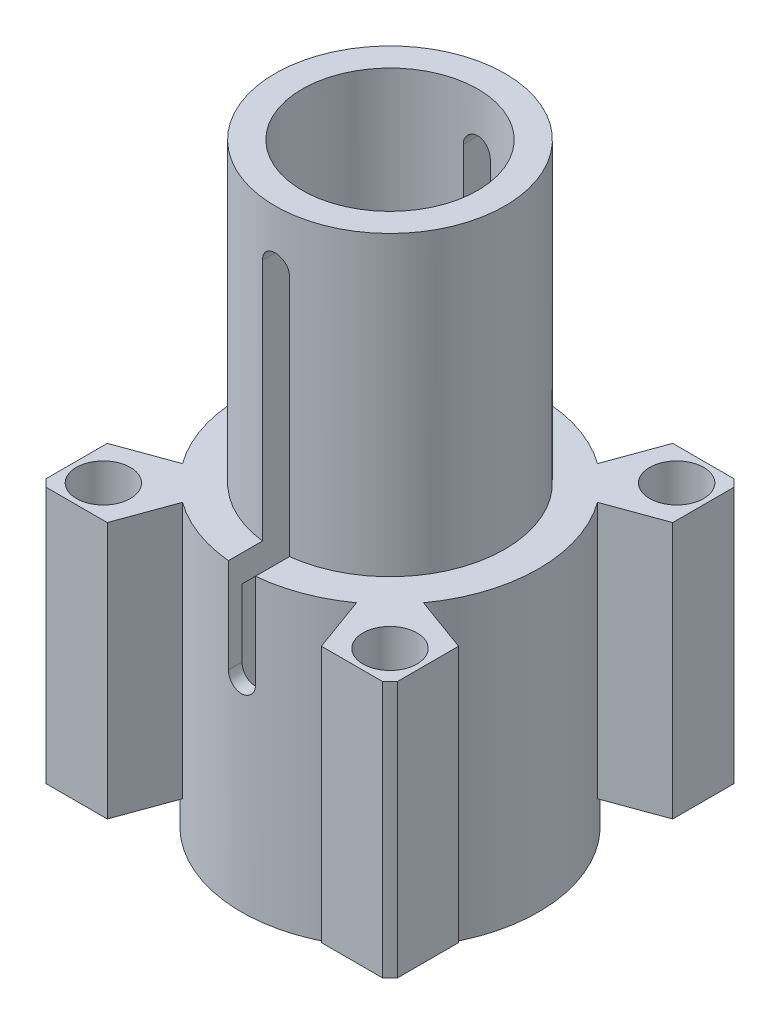
from build123d import *

# Parameters (mm, degrees)
ESQUISSE3_R      = 2
ESQUISSE3_R_2    = 10
EXTRUSION2_DEPTH = 19
EXTRUSION4_DEPTH = 27


with BuildPart() as part:
    # Esquisse1 → Révolution1 (revolve)
    with BuildSketch(Plane.XY):
        Polygon((-6.5, 17), (-6.5, 41), (-8.5, 41), (-8.5, 19), (-11, 19), (-11, -3), (-10, -3), (-10, 17), align=None)
    revolve(axis=Axis((0, 0, 0), (0, 1, 0)))

    # Esquisse3 → Extrusion2 (add)
    with BuildSketch(Plane(origin=(0, 19, 0), x_dir=(1, 0, 0), z_dir=(0, 1, 0))):
        with BuildLine():
            Line((-12.449899598, -13), (-7.924146363, -13))
            Line((-7.924146363, -13), (-6.438678833, -8.918711504))
            ThreePointArc((-6.438678833, -8.918711504), (0, -11), (6.438678833, -8.918711504))
            Line((6.438678833, -8.918711504), (7.924146363, -13))
            Line((7.924146363, -13), (12.449899598, -13))
            ThreePointArc((12.449899598, -13), (12.727922061, -12.727922061), (13, -12.449899598))
            Line((13, -12.449899598), (13, -7.924146363))
            Line((13, -7.924146363), (8.918711504, -6.438678833))
            ThreePointArc((8.918711504, -6.438678833), (11, 0), (8.918711504, 6.438678833))
            Line((8.918711504, 6.438678833), (13, 7.924146363))
            Line((13, 7.924146363), (13, 12.449899598))
            ThreePointArc((13, 12.449899598), (12.727922061, 12.727922061), (12.449899598, 13))
            Line((12.449899598, 13), (7.924146363, 13))
            Line((7.924146363, 13), (6.438678833, 8.918711504))
            ThreePointArc((6.438678833, 8.918711504), (0, 11), (-6.438678833, 8.918711504))
            Line((-6.438678833, 8.918711504), (-7.924146363, 13))
            Line((-7.924146363, 13), (-12.449899598, 13))
            ThreePointArc((-12.449899598, 13), (-12.727922061, 12.727922061), (-13, 12.449899598))
            Line((-13, 12.449899598), (-13, 7.924146363))
            Line((-13, 7.924146363), (-8.918711504, 6.438678833))
            ThreePointArc((-8.918711504, 6.438678833), (-11, 0), (-8.918711504, -6.438678833))
            Line((-8.918711504, -6.438678833), (-13, -7.924146363))
            Line((-13, -7.924146363), (-13, -12.449899598))
            ThreePointArc((-13, -12.449899598), (-12.727922061, -12.727922061), (-12.449899598, -13))
        make_face()
        with Locations((10.606601718, 10.606601718)):
            Circle(ESQUISSE3_R, mode=Mode.SUBTRACT)
        with Locations((-10.606601718, -10.606601718)):
            Circle(ESQUISSE3_R, mode=Mode.SUBTRACT)
        with Locations((-10.606601718, 10.606601718)):
            Circle(ESQUISSE3_R, mode=Mode.SUBTRACT)
        with Locations((10.606601718, -10.606601718)):
            Circle(ESQUISSE3_R, mode=Mode.SUBTRACT)
        Circle(ESQUISSE3_R_2, mode=Mode.SUBTRACT)
    extrude(amount=-EXTRUSION2_DEPTH)

    # Esquisse4 → Extrusion4 (cut, through all)
    with BuildSketch(Plane.XY.offset(13)):
        with BuildLine():
            Line((-1, 37), (-1, 12))
            ThreePointArc((-1, 12), (0, 11), (1, 12))
            Line((1, 12), (1, 37))
            ThreePointArc((1, 37), (0, 38), (-1, 37))
        make_face()
    extrude(amount=-EXTRUSION4_DEPTH, mode=Mode.SUBTRACT)


solid = part.part
